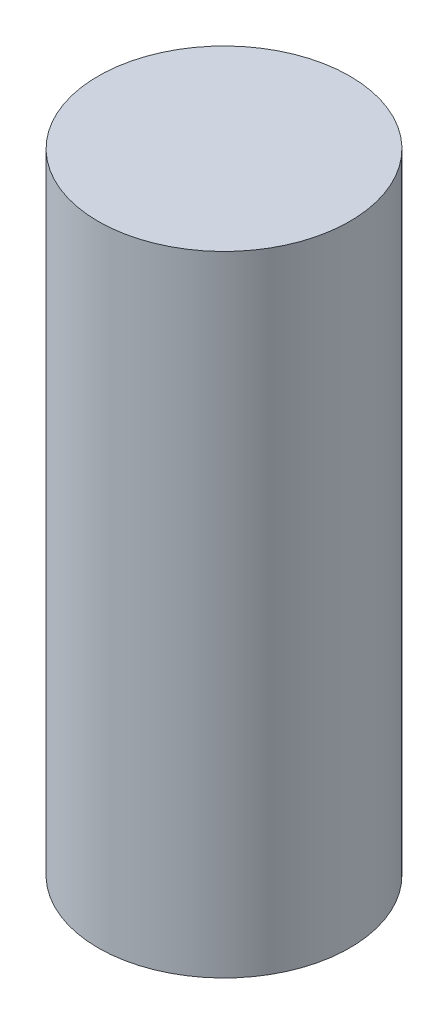
from build123d import *

# Parameters (mm, degrees)
SKETCH1_W = 1.4
SKETCH1_H = 7


with BuildPart() as part:
    # Sketch1 → Revolve1 (revolve)
    with BuildSketch(Plane.XY):
        with Locations((0.7, 3.5)):
            Rectangle(SKETCH1_W, SKETCH1_H)
    revolve(axis=Axis((0, 0, 0), (0, 1, 0)))


solid = part.part
